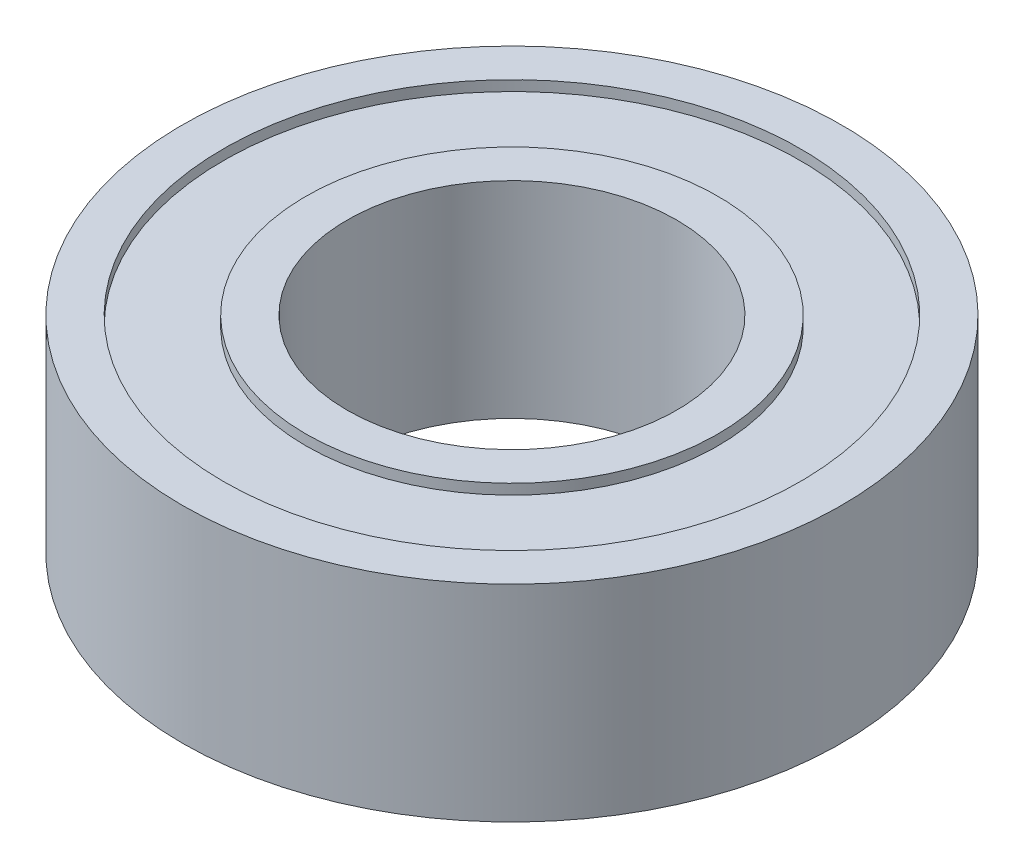
from build123d import *

# Parameters (mm, degrees)
BOSS_EXTRUDE1_DEPTH        = 2.5
BOSS_EXTRUDE1_DEPTH_BACK   = 2.5
SKETCH1_R                  = 8
SKETCH1_R_2                = 7
BOSS_EXTRUDE1_2_DEPTH      = 2.5
BOSS_EXTRUDE1_2_DEPTH_BACK = 2.5
SKETCH1_R_3                = 5
SKETCH1_R_4                = 4
BOSS_EXTRUDE2_DEPTH        = 2.25
BOSS_EXTRUDE2_DEPTH_BACK   = 2.25
SKETCH2_R                  = 7
SKETCH2_R_2                = 5


with BuildPart() as part:
    # Sketch1 → Boss-Extrude1 (new, two sides: drawn at the far end of the back side and taken through both)
    with BuildSketch(Plane(origin=(0, 0, 0), x_dir=(1, 0, 0), z_dir=(0, 1, 0)).offset(-BOSS_EXTRUDE1_DEPTH_BACK)):
        Circle(SKETCH1_R)
        Circle(SKETCH1_R_2, mode=Mode.SUBTRACT)
    extrude(amount=BOSS_EXTRUDE1_DEPTH + BOSS_EXTRUDE1_DEPTH_BACK)


with BuildPart() as body_2:
    # Sketch1 → Boss-Extrude1 2 (new, two sides: drawn at the far end of the back side and taken through both)
    with BuildSketch(Plane(origin=(0, 0, 0), x_dir=(1, 0, 0), z_dir=(0, 1, 0)).offset(-BOSS_EXTRUDE1_2_DEPTH_BACK)):
        Circle(SKETCH1_R_3)
        Circle(SKETCH1_R_4, mode=Mode.SUBTRACT)
    extrude(amount=BOSS_EXTRUDE1_2_DEPTH + BOSS_EXTRUDE1_2_DEPTH_BACK)


with BuildPart() as body_3:
    # Sketch2 → Boss-Extrude2 (new, two sides: drawn at the far end of the back side and taken through both)
    with BuildSketch(Plane(origin=(0, 0, 0), x_dir=(1, 0, 0), z_dir=(0, 1, 0)).offset(-BOSS_EXTRUDE2_DEPTH_BACK)):
        Circle(SKETCH2_R)
        Circle(SKETCH2_R_2, mode=Mode.SUBTRACT)
    extrude(amount=BOSS_EXTRUDE2_DEPTH + BOSS_EXTRUDE2_DEPTH_BACK)


solid = Compound([part.part, body_2.part, body_3.part])
